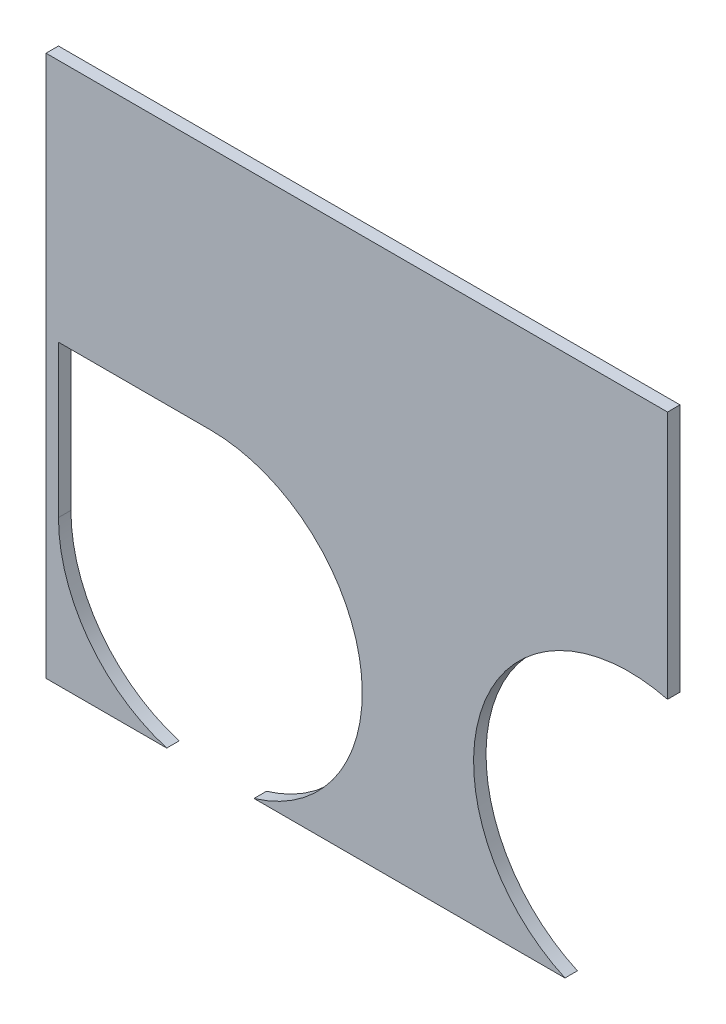
from build123d import *

# Parameters (mm, degrees)
SKETCH1_W           = 249.6
SKETCH1_H           = 267.4
BOSS_EXTRUDE1_DEPTH = 5
CUT_EXTRUDE3_DEPTH  = 6


with BuildPart() as part:
    # Sketch1 → Boss-Extrude1 (new body)
    with BuildSketch(Plane.XY):
        with Locations((124.8, -133.7)):
            Rectangle(SKETCH1_W, SKETCH1_H)
    extrude(amount=BOSS_EXTRUDE1_DEPTH)

    # Sketch5 → Cut-Extrude3 (cut, through all)
    with BuildSketch(Plane.XY.offset(5)):
        with BuildLine():
            Line((124.8, -267.4), (249.6, -267.4))
            Line((249.6, -267.4), (249.6, -99.925464159))
            ThreePointArc((249.6, -99.925464159), (175.224742578, -139.824828971), (208.410715021, -217.428498098))
            Line((208.410715021, -217.428498098), (83.524571607, -217.428498098))
            ThreePointArc((83.524571607, -217.428498098), (126.353700731, -150.143883017), (66, -98))
            Line((66, -98), (5, -98))
            Line((5, -98), (5, -159))
            ThreePointArc((5, -159), (17.061268569, -195.414290683), (48.475428393, -217.428498098))
            Line((48.475428393, -217.428498098), (0, -217.428498098))
            Line((0, -217.428498098), (0, -267.4))
            Line((0, -267.4), (124.8, -267.4))
        make_face()
    extrude(amount=-CUT_EXTRUDE3_DEPTH, mode=Mode.SUBTRACT)


solid = part.part
